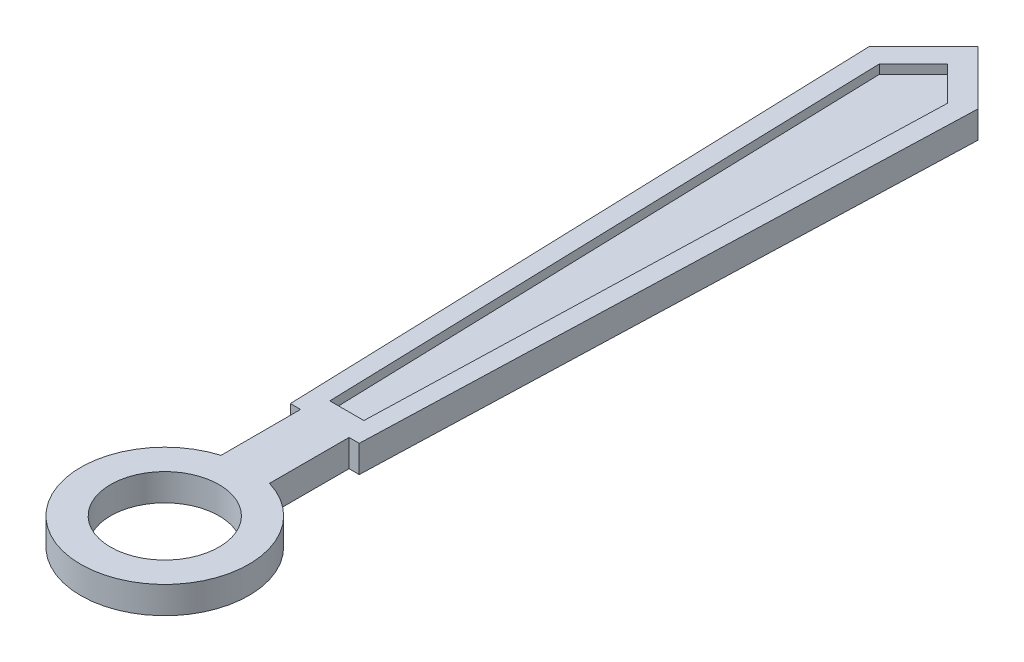
from build123d import *

# Parameters (mm, degrees)
BOSS_EXTRUDE1_DEPTH = 0.3
SKETCH2_R           = 0.6
CUT_EXTRUDE2_DEPTH  = 0.3
CUT_EXTRUDE3_DEPTH  = 0.1


with BuildPart() as part:
    # Sketch1 → Boss-Extrude1 (new body)
    with BuildSketch(Plane(origin=(0, 0, 0), x_dir=(1, 0, 0), z_dir=(0, 1, 0))):
        with BuildLine():
            Line((-0.268357858, 1.770915819), (-0.268357858, 0.8908721))
            ThreePointArc((-0.268357858, 0.8908721), (0, -0.93041337), (0.268357858, 0.8908721))
            Line((0.268357858, 0.8908721), (0.268357858, 1.770915819))
            Line((0.268357858, 1.770915819), (0.380994594, 1.770915819))
            Line((0.380994594, 1.770915819), (0.6, 8.4))
            Line((0.6, 8.4), (0, 9))
            Line((0, 9), (-0.6, 8.4))
            Line((-0.6, 8.4), (-0.380994594, 1.770915819))
            Line((-0.380994594, 1.770915819), (-0.268357858, 1.770915819))
        make_face()
    extrude(amount=BOSS_EXTRUDE1_DEPTH)

    # Sketch2 → Cut-Extrude2 (cut)
    with BuildSketch(Plane(origin=(0, 0, 0), x_dir=(1, 0, 0), z_dir=(0, 1, 0))):
        Circle(SKETCH2_R)
    extrude(amount=CUT_EXTRUDE2_DEPTH, mode=Mode.SUBTRACT)

    # Sketch4 → Cut-Extrude3 (cut)
    with BuildSketch(Plane(origin=(0, 0.3, 0), x_dir=(1, 0, 0), z_dir=(0, 1, 0))):
        Polygon((0, 8.662563121), (0.377183269, 8.285379851), (0.188591635, 2.014863516), (-0.188591635, 2.014863516), (-0.377183269, 8.285379851), align=None)
    extrude(amount=-CUT_EXTRUDE3_DEPTH, mode=Mode.SUBTRACT)


solid = part.part
